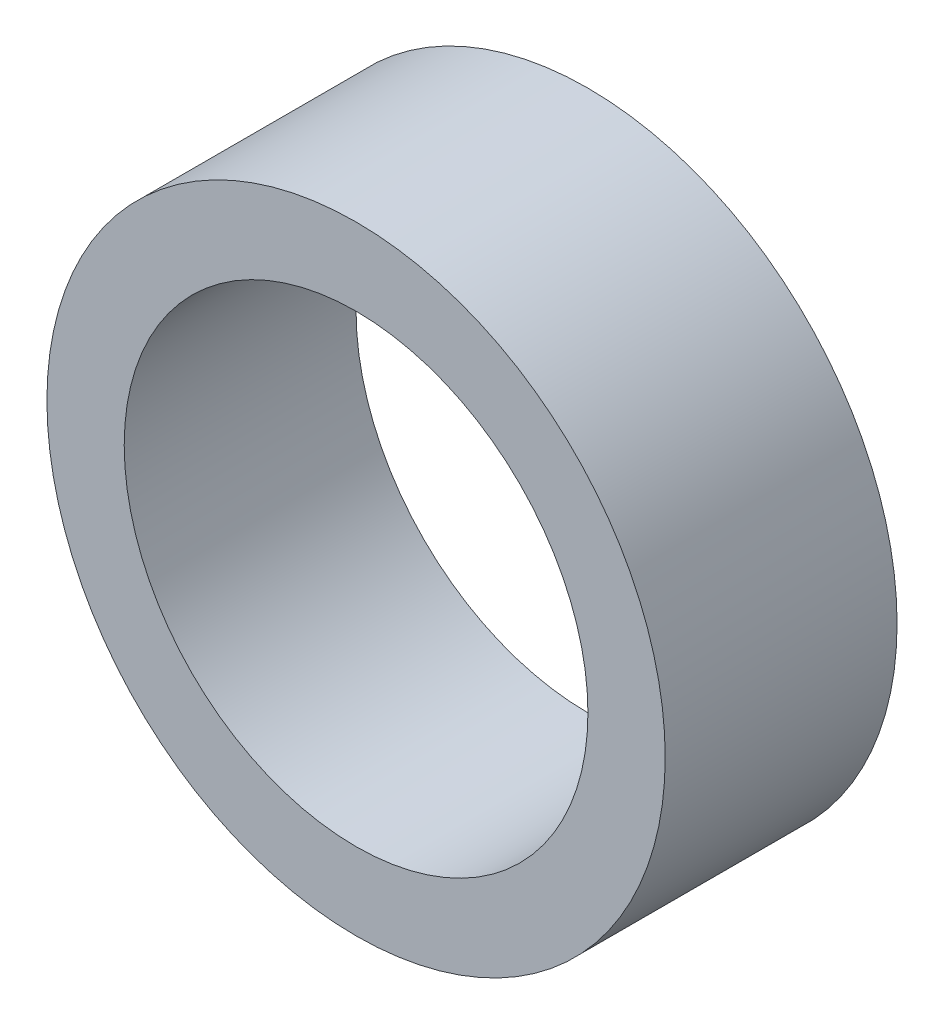
from build123d import *

# Parameters (mm, degrees)
SKETCH3_R           = 12.7
SKETCH3_R_2         = 9.525
BOSS_EXTRUDE1_DEPTH = 4.7625


with BuildPart() as part:
    # Sketch3 → Boss-Extrude1 (new body, symmetric)
    with BuildSketch(Plane.XY):
        Circle(SKETCH3_R)
        Circle(SKETCH3_R_2, mode=Mode.SUBTRACT)
    extrude(amount=BOSS_EXTRUDE1_DEPTH, both=True)


solid = part.part
